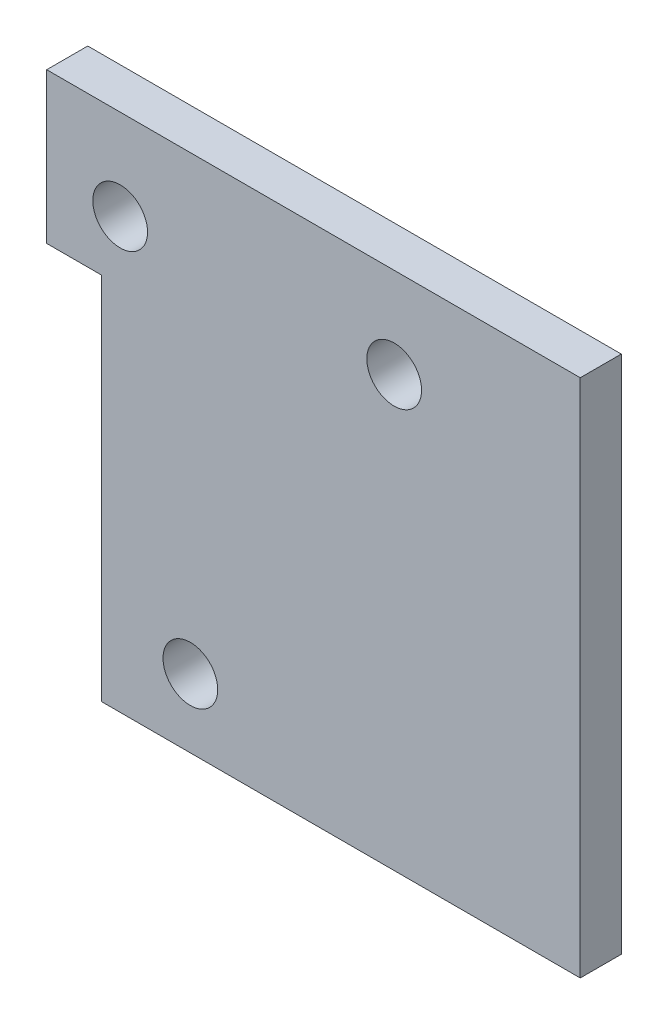
from build123d import *

# Parameters (mm, degrees)
BOSS_EXTRUDE1_DEPTH = 3
SKETCH2_R           = 2
CUT_EXTRUDE1_DEPTH  = 3
SKETCH3_R           = 2.5
SKETCH3_R_2         = 2
BOSS_EXTRUDE2_DEPTH = 6


with BuildPart() as part:
    # Sketch1 → Boss-Extrude1 (new body)
    with BuildSketch(Plane.XY):
        Polygon((4, 0), (39, 0), (39, 38), (0, 38), (0, 27), (4, 27), align=None)
    extrude(amount=BOSS_EXTRUDE1_DEPTH)

    # Sketch2 → Cut-Extrude1 (cut)
    with BuildSketch(Plane.XY.offset(3)):
        with Locations((5.37, 31.4)):
            Circle(SKETCH2_R)
        with Locations((25.4, 31.4)):
            Circle(SKETCH2_R)
        with Locations((10.5, 5)):
            Circle(SKETCH2_R)
    extrude(amount=-CUT_EXTRUDE1_DEPTH, mode=Mode.SUBTRACT)

    # Sketch3 → Boss-Extrude2 (add)
    with BuildSketch(Plane.XY.offset(3)):
        with Locations((5.37, 31.4)):
            Circle(SKETCH3_R)
        with Locations((5.37, 31.4)):
            Circle(SKETCH3_R_2, mode=Mode.SUBTRACT)
        with Locations((25.4, 31.4)):
            Circle(SKETCH3_R)
        with Locations((25.4, 31.4)):
            Circle(SKETCH3_R_2, mode=Mode.SUBTRACT)
        with Locations((10.5, 5)):
            Circle(SKETCH3_R)
        with Locations((10.5, 5)):
            Circle(SKETCH3_R_2, mode=Mode.SUBTRACT)
    extrude(amount=-BOSS_EXTRUDE2_DEPTH)


solid = part.part
